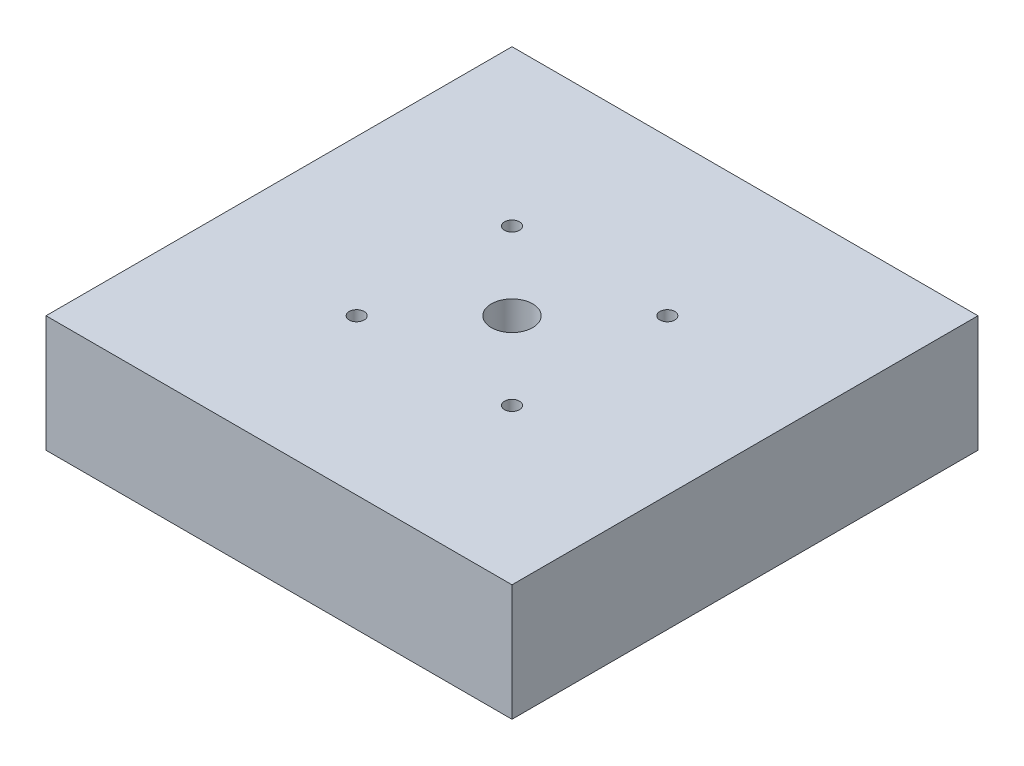
from build123d import *

# Parameters (mm, degrees)
SKETCH1_W               = 76.2
SKETCH1_H               = 76.2
BOSS_EXTRUDE1_DEPTH     = 19.05
F_1_4_CLEARANCE_HOLE1_D = 6.7564
F_2_CLEARANCE_HOLE1_D   = 2.4384
F_2_CLEARANCE_HOLE2_D   = 2.4384


with BuildPart() as part:
    # Sketch1 → Boss-Extrude1 (new body)
    with BuildSketch(Plane(origin=(0, 0, 0), x_dir=(1, 0, 0), z_dir=(0, 1, 0))):
        Rectangle(SKETCH1_W, SKETCH1_H)
    extrude(amount=BOSS_EXTRUDE1_DEPTH)

    # 1/4 Clearance Hole1 (through all)
    with Locations(Plane(origin=(0, 19.05, 0), x_dir=(1, 0, 0), z_dir=(0, 1, 0))):
        with Locations((0, 0)):
            Hole(F_1_4_CLEARANCE_HOLE1_D / 2)

    # #2 Clearance Hole1 (through all)
    with Locations(Plane(origin=(0, 19.05, 0), x_dir=(1, 0, 0), z_dir=(0, 1, 0))):
        with Locations((-12.7, 12.7), (0, 0)):
            Hole(F_2_CLEARANCE_HOLE1_D / 2)

    # #2 Clearance Hole2 (through all)
    with Locations(Plane(origin=(0, 19.05, 0), x_dir=(1, 0, 0), z_dir=(0, 1, 0))):
        with Locations((12.7, 12.7), (-12.7, -12.7), (12.7, -12.7)):
            Hole(F_2_CLEARANCE_HOLE2_D / 2)


solid = part.part
